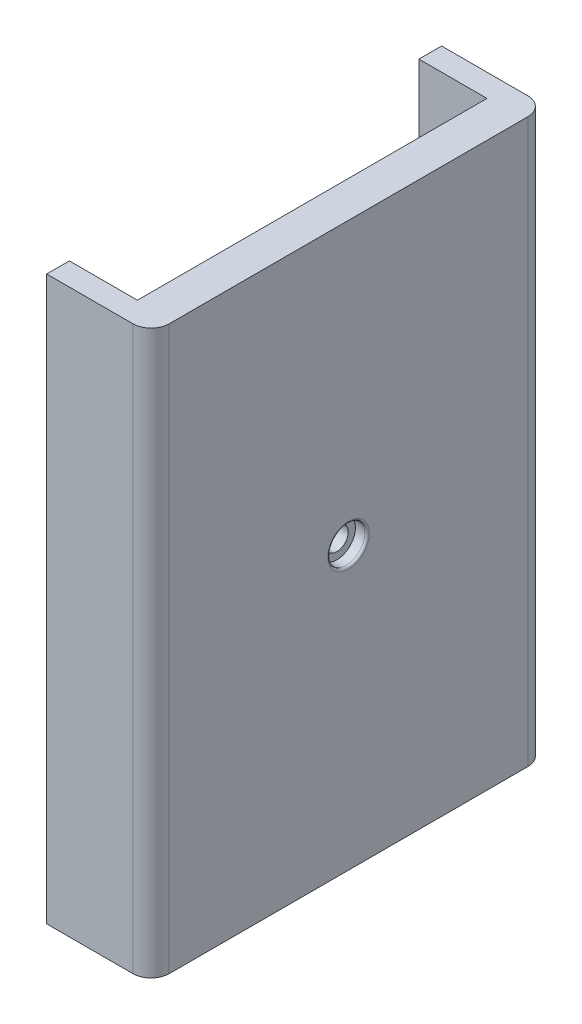
from build123d import *

# Parameters (mm, degrees)
SKETCH1_W           = 12
SKETCH1_H           = 18.25
SKETCH2_R           = 3.7145
CUT_EXTRUDE1_DEPTH  = 8.5725
SKETCH3_W           = 87
SKETCH3_H           = 124
BOSS_EXTRUDE1_DEPTH = 8
FILLET1_R           = 4
SKETCH6_R           = 13.15
CUT_EXTRUDE2_DEPTH  = 12
SKETCH12_R          = 4.075
CUT_EXTRUDE6_DEPTH  = 2.56
SKETCH12_6_R        = 2.5
CUT_EXTRUDE7_DEPTH  = 8
FILLET2_R           = 0.5
SKETCH15_W          = 5
SKETCH15_H          = 124
BOSS_EXTRUDE2_DEPTH = 15


with BuildPart() as part:
    # Sketch1 → Revolve1 (revolve)
    with BuildSketch(Plane.XY):
        with Locations((14.255, 9.125)):
            Rectangle(SKETCH1_W, SKETCH1_H)
    revolve(axis=Axis((8.255, 0, 0), (1, 0, 0)))

    # Sketch2 → Cut-Extrude1 (cut)
    with BuildSketch(Plane.ZY.offset(-8.255)):
        Circle(SKETCH2_R)
    extrude(amount=-CUT_EXTRUDE1_DEPTH, mode=Mode.SUBTRACT)

    # Sketch6 → Cut-Extrude2 (cut)
    with BuildSketch(Plane.ZY.offset(-8.255)):
        Circle(SKETCH6_R)
    extrude(amount=-CUT_EXTRUDE2_DEPTH, mode=Mode.SUBTRACT)


with BuildPart() as body_2:
    # Sketch3 → Boss-Extrude1 (new body)
    with BuildSketch(Plane(origin=(20.255, 0, 0), x_dir=(0, 0, -1), z_dir=(1, 0, 0))):
        Rectangle(SKETCH3_W, SKETCH3_H)
    extrude(amount=BOSS_EXTRUDE1_DEPTH)

    # Fillet1
    fillet1_edges = [body_2.edges().sort_by_distance(p)[0] for p in [
        (28.255, 0, -43.5),
        (28.255, 0, 43.5),
    ]]
    fillet(fillet1_edges, radius=FILLET1_R)

    # Sketch12 → Cut-Extrude6 (cut)
    with BuildSketch(Plane(origin=(28.255, 0, 0), x_dir=(0, 0, -1), z_dir=(1, 0, 0))):
        Circle(SKETCH12_R)
    extrude(amount=-CUT_EXTRUDE6_DEPTH, mode=Mode.SUBTRACT)

    # Sketch12_6 → Cut-Extrude7 (cut)
    with BuildSketch(Plane(origin=(28.255, 0, 0), x_dir=(0, 0, -1), z_dir=(1, 0, 0))):
        Circle(SKETCH12_6_R)
    extrude(amount=-CUT_EXTRUDE7_DEPTH, mode=Mode.SUBTRACT)

    # Fillet2
    fillet2_edges = [body_2.edges().sort_by_distance(p)[0] for p in [
        (28.255, 0, 4.075),
    ]]
    fillet(fillet2_edges, radius=FILLET2_R)


with BuildPart() as part_1:
    add(part.part)

    # Combine1: union body 2
    add(body_2.part)

    # Sketch15 → Boss-Extrude2 (add)
    with BuildSketch(Plane.ZY.offset(-20.255)):
        with Locations((-41, 0)):
            Rectangle(SKETCH15_W, SKETCH15_H)
        with Locations((41, 0)):
            Rectangle(SKETCH15_W, SKETCH15_H)
    extrude(amount=BOSS_EXTRUDE2_DEPTH)


solid = part_1.part
